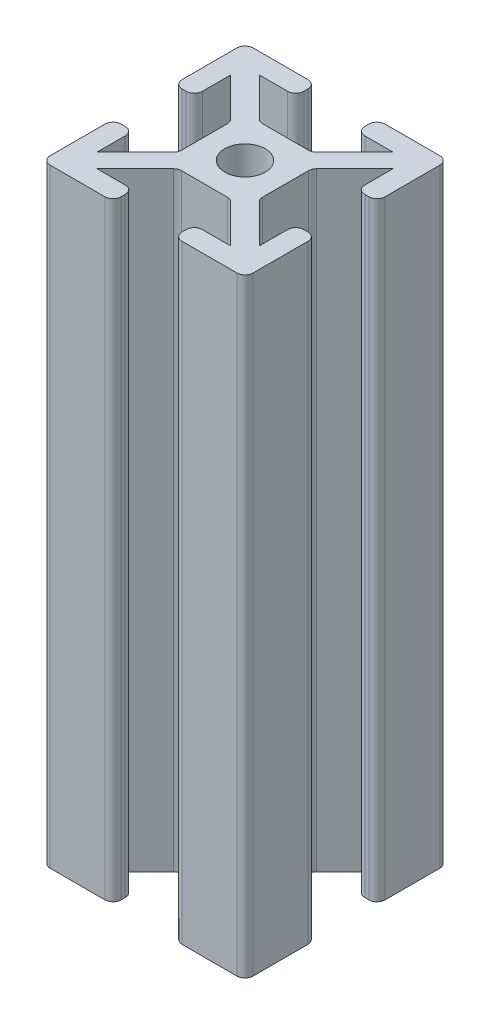
from build123d import *

# Parameters (mm, degrees)
SKETCH1_R           = 2
PROFILE_4X4_1_DEPTH = 60


with BuildPart() as part:
    # Sketch1 → Profile 4X4(1) (new body)
    with BuildSketch(Plane.XZ.offset(-34)):
        with BuildLine():
            Line((-3, 9.2), (-3, 8.8))
            ThreePointArc((-3, 8.8), (-3.234314575, 8.234314575), (-3.8, 8))
            Line((-3.8, 8), (-6.585786438, 8))
            Line((-6.585786438, 8), (-2.820101013, 4.234314575))
            ThreePointArc((-2.820101013, 4.234314575), (-2.560562334, 4.060896374), (-2.254415588, 4))
            Line((-2.254415588, 4), (2.254415588, 4))
            ThreePointArc((2.254415588, 4), (2.560562334, 4.060896374), (2.820101013, 4.234314575))
            Line((2.820101013, 4.234314575), (6.585786438, 8))
            Line((6.585786438, 8), (3.8, 8))
            ThreePointArc((3.8, 8), (3.234314575, 8.234314575), (3, 8.8))
            Line((3, 8.8), (3, 9.2))
            ThreePointArc((3, 9.2), (3.234314575, 9.765685425), (3.8, 10))
            Line((3.8, 10), (9.2, 10))
            ThreePointArc((9.2, 10), (9.765685425, 9.765685425), (10, 9.2))
            Line((10, 9.2), (10, 3.8))
            ThreePointArc((10, 3.8), (9.765685425, 3.234314575), (9.2, 3))
            Line((9.2, 3), (8.8, 3))
            ThreePointArc((8.8, 3), (8.234314575, 3.234314575), (8, 3.8))
            Line((8, 3.8), (8, 6.585786438))
            Line((8, 6.585786438), (4.234314575, 2.820101013))
            ThreePointArc((4.234314575, 2.820101013), (4.060896374, 2.560562334), (4, 2.254415588))
            Line((4, 2.254415588), (4, -2.254415588))
            ThreePointArc((4, -2.254415588), (4.060896374, -2.560562334), (4.234314575, -2.820101013))
            Line((4.234314575, -2.820101013), (8, -6.585786438))
            Line((8, -6.585786438), (8, -3.8))
            ThreePointArc((8, -3.8), (8.234314575, -3.234314575), (8.8, -3))
            Line((8.8, -3), (9.2, -3))
            ThreePointArc((9.2, -3), (9.765685425, -3.234314575), (10, -3.8))
            Line((10, -3.8), (10, -9.2))
            ThreePointArc((10, -9.2), (9.765685425, -9.765685425), (9.2, -10))
            Line((9.2, -10), (3.8, -10))
            ThreePointArc((3.8, -10), (3.234314575, -9.765685425), (3, -9.2))
            Line((3, -9.2), (3, -8.8))
            ThreePointArc((3, -8.8), (3.234314575, -8.234314575), (3.8, -8))
            Line((3.8, -8), (6.585786438, -8))
            Line((6.585786438, -8), (2.820101013, -4.234314575))
            ThreePointArc((2.820101013, -4.234314575), (2.560562334, -4.060896374), (2.254415588, -4))
            Line((2.254415588, -4), (-2.254415588, -4))
            ThreePointArc((-2.254415588, -4), (-2.560562334, -4.060896374), (-2.820101013, -4.234314575))
            Line((-2.820101013, -4.234314575), (-6.585786438, -8))
            Line((-6.585786438, -8), (-3.8, -8))
            ThreePointArc((-3.8, -8), (-3.234314575, -8.234314575), (-3, -8.8))
            Line((-3, -8.8), (-3, -9.2))
            ThreePointArc((-3, -9.2), (-3.234314575, -9.765685425), (-3.8, -10))
            Line((-3.8, -10), (-9.2, -10))
            ThreePointArc((-9.2, -10), (-9.765685425, -9.765685425), (-10, -9.2))
            Line((-10, -9.2), (-10, -3.8))
            ThreePointArc((-10, -3.8), (-9.765685425, -3.234314575), (-9.2, -3))
            Line((-9.2, -3), (-8.8, -3))
            ThreePointArc((-8.8, -3), (-8.234314575, -3.234314575), (-8, -3.8))
            Line((-8, -3.8), (-8, -6.585786438))
            Line((-8, -6.585786438), (-4.234314575, -2.820101013))
            ThreePointArc((-4.234314575, -2.820101013), (-4.060896374, -2.560562334), (-4, -2.254415588))
            Line((-4, -2.254415588), (-4, 2.254415588))
            ThreePointArc((-4, 2.254415588), (-4.060896374, 2.560562334), (-4.234314575, 2.820101013))
            Line((-4.234314575, 2.820101013), (-8, 6.585786438))
            Line((-8, 6.585786438), (-8, 3.8))
            ThreePointArc((-8, 3.8), (-8.234314575, 3.234314575), (-8.8, 3))
            Line((-8.8, 3), (-9.2, 3))
            ThreePointArc((-9.2, 3), (-9.765685425, 3.234314575), (-10, 3.8))
            Line((-10, 3.8), (-10, 9.2))
            ThreePointArc((-10, 9.2), (-9.765685425, 9.765685425), (-9.2, 10))
            Line((-9.2, 10), (-3.8, 10))
            ThreePointArc((-3.8, 10), (-3.234314575, 9.765685425), (-3, 9.2))
        make_face()
        Circle(SKETCH1_R, mode=Mode.SUBTRACT)
    extrude(amount=PROFILE_4X4_1_DEPTH)


solid = part.part
